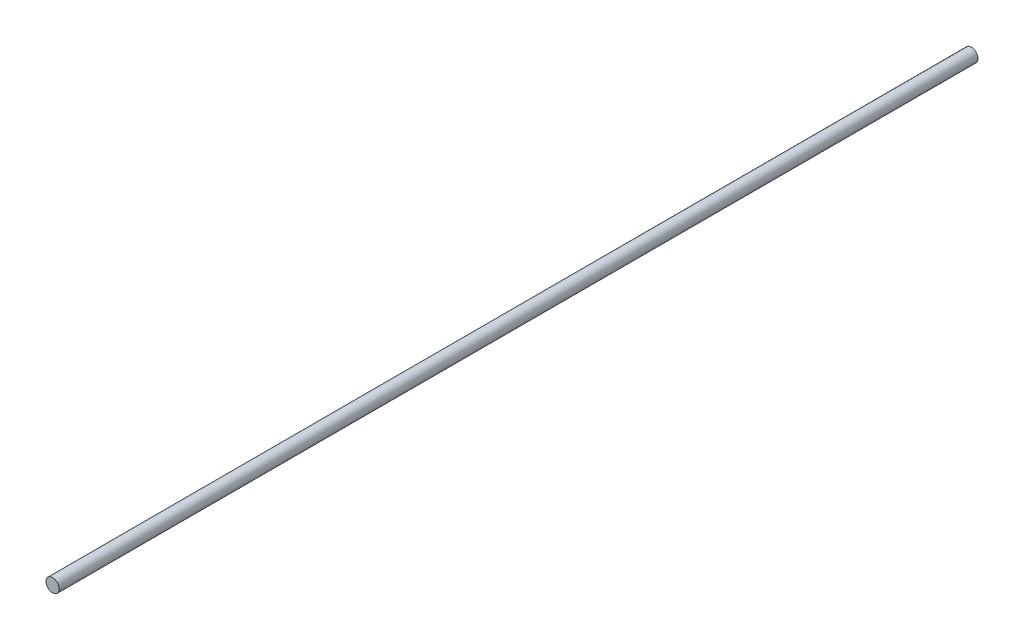
from build123d import *

# Parameters (mm, degrees)
CROQUIS1_R              = 4
SALIENTE_EXTRUIR1_DEPTH = 555


with BuildPart() as part:
    # Croquis1 → Saliente-Extruir1 (new body)
    with BuildSketch(Plane.XY):
        Circle(CROQUIS1_R)
    extrude(amount=-SALIENTE_EXTRUIR1_DEPTH)


solid = part.part
